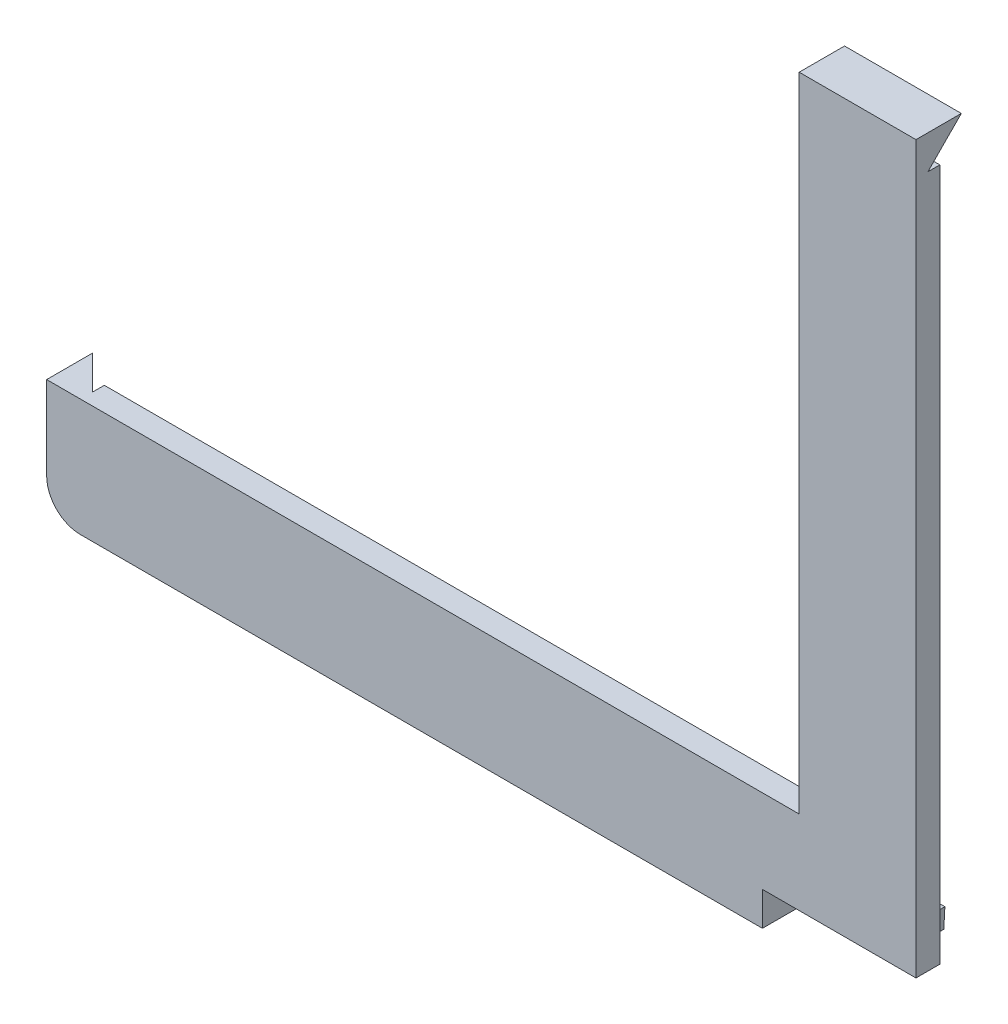
from build123d import *
from build123d.topology import SkipClean

# Parameters (mm, degrees)
BOSS_EXTRUDE1_START = 24.318234
BOSS_EXTRUDE1_DEPTH = 4
BOSS_EXTRUDE2_DEPTH = 14.010881
REVOLVE1_ANGLE      = 90
BOSS_EXTRUDE3_DEPTH = 114.273182
BOSS_EXTRUDE4_DEPTH = 19.567345
BOSS_EXTRUDE5_DEPTH = 2.39999941


with BuildPart() as part:
    # Sketch4 → Boss-Extrude1 (new body)
    with BuildSketch(Plane.XY.offset(-21.918234102).offset(BOSS_EXTRUDE1_START)):
        Polygon((194.484495585, -141.539185417), (194.484495585, -127.528304219), (314.919807208, -127.528304219), (314.919807208, -25.539185417), (334.487155432, -25.539185417), (334.487155432, -127.528304219), (334.487155432, -141.539185417), align=None)
    extrude(amount=BOSS_EXTRUDE1_DEPTH)

    # Sketch5 → Boss-Extrude2 (add)
    with SkipClean():  # the faces are left unmerged after this step: merging them gives an invalid solid
        with BuildSketch(Plane(origin=(0, -127.528304219, 0), x_dir=(1, 0, 0), z_dir=(0, 1, 0))):
            Polygon((194.484495585, -4.39999941), (188.825701169, 1.263814406), (188.825701169, -6.39999941), (194.484495585, -6.39999941), align=None)
        extrude(amount=-BOSS_EXTRUDE2_DEPTH)

    # Sketch6 → Revolve1 (revolve)
    with BuildSketch(Plane.XZ.offset(141.539185417)):
        Polygon((188.825701169, -1.263814406), (194.484495585, 4.39999941), (194.484495585, 6.39999941), (188.825701169, 6.39999941), align=None)
    revolve(axis=Axis((194.484495585, -141.539185417, 4.39999941), (0, 0, 1)), revolution_arc=REVOLVE1_ANGLE)

    # Sketch7 → Boss-Extrude3 (add)
    with BuildSketch(Plane(origin=(194.484495585, 0, 0), x_dir=(0, 0, -1), z_dir=(1, 0, 0))):
        Polygon((-6.39999941, -147.197979834), (1.263814406, -147.197979834), (-4.39999941, -141.539185417), (-6.39999941, -141.539185417), align=None)
    extrude(amount=BOSS_EXTRUDE3_DEPTH)

    # Sketch9 → Boss-Extrude4 (add)
    with BuildSketch(Plane(origin=(334.487155432, 0, 0), x_dir=(0, 0, -1), z_dir=(1, 0, 0))):
        Polygon((-4.39999941, -25.539185417), (1.201014861, -19.877880744), (-6.39999941, -19.877880744), (-6.39999941, -25.539185417), align=None)
    extrude(amount=-BOSS_EXTRUDE4_DEPTH)


with BuildPart() as boss_extrude5_tool:
    # Sketch11 → Boss-Extrude5 (new body)
    with BuildSketch(Plane(origin=(0, 0, 2.39999941), x_dir=(-1, 0, 0), z_dir=(0, 0, -1))):
        Polygon((-197.504878741, -135.167945919), (-197.504878741, -138.539185417), (-332.752260863, -138.539185417), (-332.932155432, -135.167945919), align=None)
    extrude(amount=BOSS_EXTRUDE5_DEPTH)


with BuildPart() as part_1:
    add(part.part)


with BuildPart() as part_2:
    # Boss-Extrude5: joined with boss_extrude5_tool
    add(part_1.part.fuse(boss_extrude5_tool.part, tol=0.00001))


solid = part_2.part
